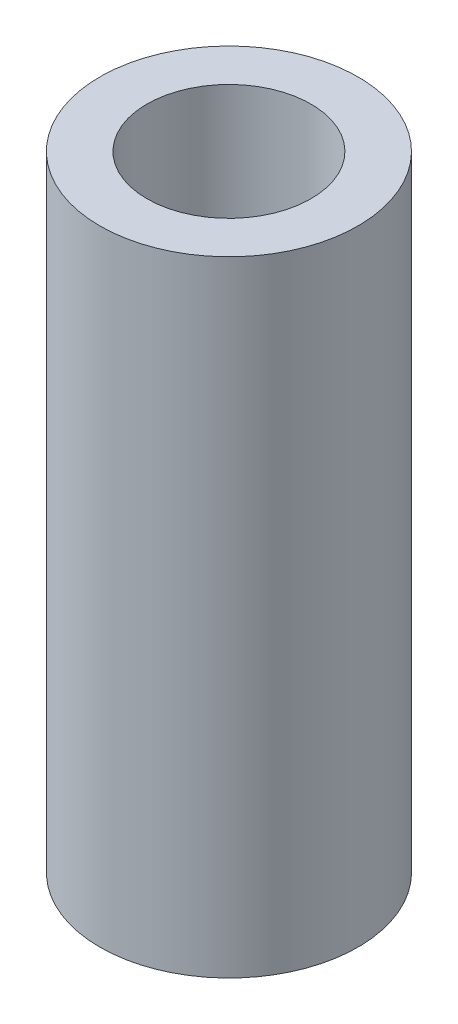
from build123d import *

# Parameters (mm, degrees)
SKETCH1_R           = 3.937
SKETCH1_R_2         = 2.5019
BOSS_EXTRUDE1_DEPTH = 19.05


with BuildPart() as part:
    # Sketch1 → Boss-Extrude1 (new body)
    with BuildSketch(Plane(origin=(0, 0, 0), x_dir=(1, 0, 0), z_dir=(0, 1, 0))):
        Circle(SKETCH1_R)
        Circle(SKETCH1_R_2, mode=Mode.SUBTRACT)
    extrude(amount=BOSS_EXTRUDE1_DEPTH)


solid = part.part
